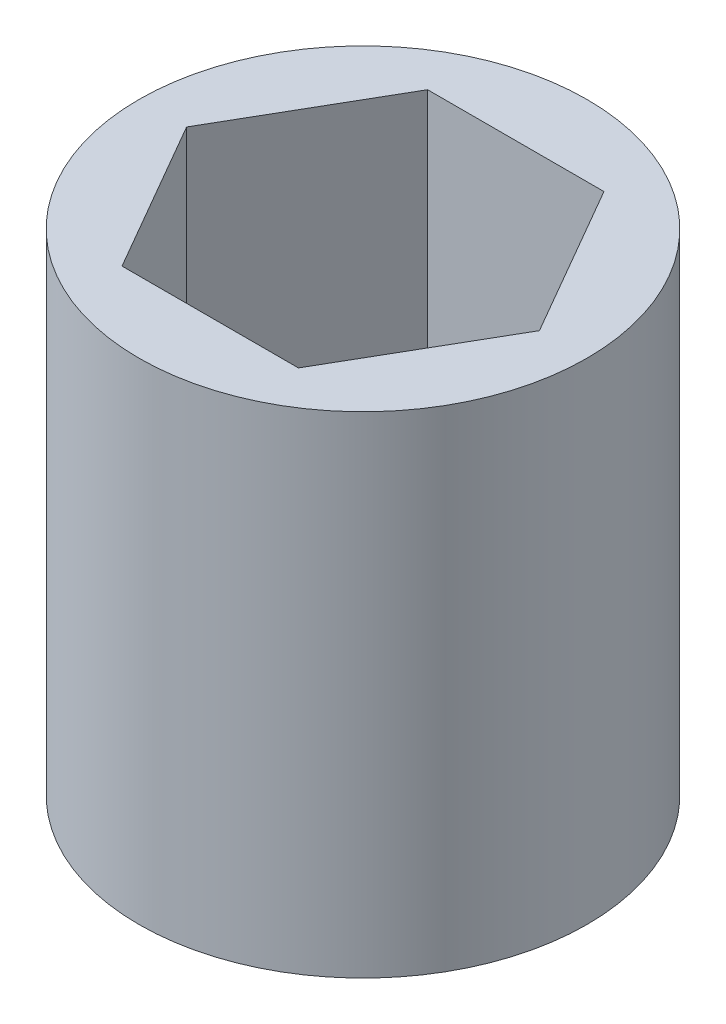
from build123d import *

# Parameters (mm, degrees)
SKETCH1_R           = 3.4925
BOSS_EXTRUDE1_DEPTH = 3.8227


with BuildPart() as part:
    # Sketch1 → Boss-Extrude1 (new body, symmetric)
    with BuildSketch(Plane(origin=(0, 0, 0), x_dir=(1, 0, 0), z_dir=(0, 1, 0))):
        Circle(SKETCH1_R)
        Polygon((1.374815329, -2.38125), (2.749630657, 0), (1.374815329, 2.38125), (-1.374815329, 2.38125), (-2.749630657, 0), (-1.374815329, -2.38125), align=None, mode=Mode.SUBTRACT)
    extrude(amount=BOSS_EXTRUDE1_DEPTH, both=True)


solid = part.part
